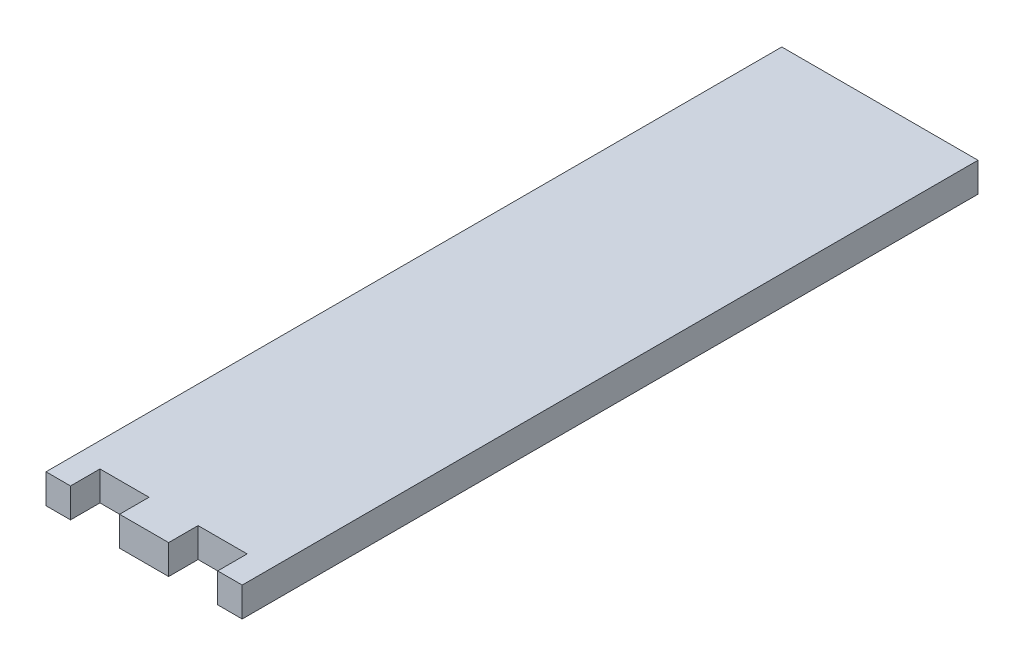
from build123d import *

# Parameters (mm, degrees)
SKETCH1_W           = 20
SKETCH1_H           = 75
BOSS_EXTRUDE1_DEPTH = 3
CUT_EXTRUDE1_START  = -4
SKETCH2_W           = 5
SKETCH2_H           = 3
CUT_EXTRUDE1_DEPTH  = 5


with BuildPart() as part:
    # Sketch1 → Boss-Extrude1 (new body)
    with BuildSketch(Plane(origin=(0, 0, 0), x_dir=(1, 0, 0), z_dir=(0, 1, 0))):
        Rectangle(SKETCH1_W, SKETCH1_H)
    extrude(amount=BOSS_EXTRUDE1_DEPTH)

    # Sketch2 → Cut-Extrude1 (cut)
    with BuildSketch(Plane.XZ.offset(CUT_EXTRUDE1_START)):
        with Locations((-5, 36)):
            Rectangle(SKETCH2_W, SKETCH2_H)
    cut_extrude1 = extrude(amount=CUT_EXTRUDE1_DEPTH, mode=Mode.SUBTRACT)

    # Mirror1: Cut-Extrude1 across plane
    add(cut_extrude1.mirror(Plane(origin=(0, 0, 0), x_dir=(0, 0, 1), z_dir=(1, 0, 0))), mode=Mode.SUBTRACT)


solid = part.part
